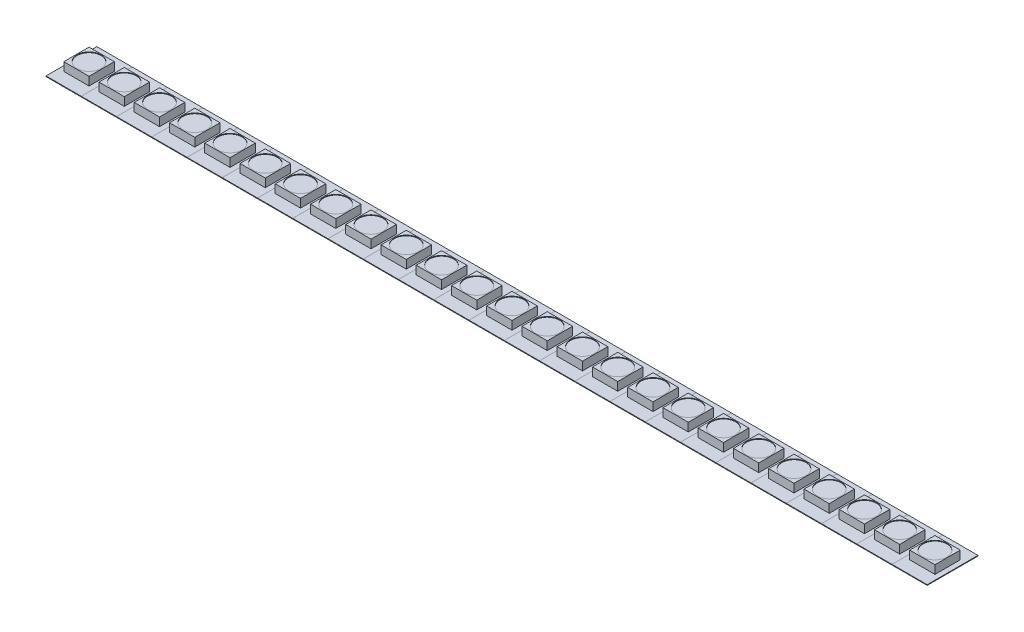
from build123d import *

# Parameters (mm, degrees)
SKETCH1_W           = 6.9088
SKETCH1_H           = 9.9568
BOSS_EXTRUDE1_DEPTH = 0.127
SKETCH3_W           = 4.953
SKETCH3_H           = 4.953
BOSS_EXTRUDE3_DEPTH = 1.651
SKETCH5_R           = 2.348345572
CUT_EXTRUDE1_DEPTH  = 0.127
LPATTERN1_COUNT     = 25
LPATTERN1_PITCH     = 6.9088


with BuildPart() as part:
    # Sketch1 → Boss-Extrude1 (new body)
    with BuildSketch(Plane(origin=(0, 0, 0), x_dir=(1, 0, 0), z_dir=(0, 1, 0))):
        Rectangle(SKETCH1_W, SKETCH1_H)
    extrude(amount=BOSS_EXTRUDE1_DEPTH)

    # Sketch3 → Boss-Extrude3 (add)
    with BuildSketch(Plane(origin=(0, 0.127, 0), x_dir=(1, 0, 0), z_dir=(0, 1, 0))):
        Rectangle(SKETCH3_W, SKETCH3_H)
    extrude(amount=BOSS_EXTRUDE3_DEPTH)

    # Sketch5 → Cut-Extrude1 (cut)
    with BuildSketch(Plane(origin=(0, 1.778, 0), x_dir=(1, 0, 0), z_dir=(0, 1, 0))):
        Circle(SKETCH5_R)
    extrude(amount=-CUT_EXTRUDE1_DEPTH, mode=Mode.SUBTRACT)


with BuildPart() as lpattern1_1:
    # LPattern1: pattern copy
    add(part.part.moved(Location(Vector(1, 0, 0) * (1 * LPATTERN1_PITCH))))


with BuildPart() as lpattern1_2:
    # LPattern1: pattern copy
    add(part.part.moved(Location(Vector(1, 0, 0) * (2 * LPATTERN1_PITCH))))


with BuildPart() as lpattern1_3:
    # LPattern1: pattern copy
    add(part.part.moved(Location(Vector(1, 0, 0) * (3 * LPATTERN1_PITCH))))


with BuildPart() as lpattern1_4:
    # LPattern1: pattern copy
    add(part.part.moved(Location(Vector(1, 0, 0) * (4 * LPATTERN1_PITCH))))


with BuildPart() as lpattern1_5:
    # LPattern1: pattern copy
    add(part.part.moved(Location(Vector(1, 0, 0) * (5 * LPATTERN1_PITCH))))


with BuildPart() as lpattern1_6:
    # LPattern1: pattern copy
    add(part.part.moved(Location(Vector(1, 0, 0) * (6 * LPATTERN1_PITCH))))


with BuildPart() as lpattern1_7:
    # LPattern1: pattern copy
    add(part.part.moved(Location(Vector(1, 0, 0) * (7 * LPATTERN1_PITCH))))


with BuildPart() as lpattern1_8:
    # LPattern1: pattern copy
    add(part.part.moved(Location(Vector(1, 0, 0) * (8 * LPATTERN1_PITCH))))


with BuildPart() as lpattern1_9:
    # LPattern1: pattern copy
    add(part.part.moved(Location(Vector(1, 0, 0) * (9 * LPATTERN1_PITCH))))


with BuildPart() as lpattern1_10:
    # LPattern1: pattern copy
    add(part.part.moved(Location(Vector(1, 0, 0) * (10 * LPATTERN1_PITCH))))


with BuildPart() as lpattern1_11:
    # LPattern1: pattern copy
    add(part.part.moved(Location(Vector(1, 0, 0) * (11 * LPATTERN1_PITCH))))


with BuildPart() as lpattern1_12:
    # LPattern1: pattern copy
    add(part.part.moved(Location(Vector(1, 0, 0) * (12 * LPATTERN1_PITCH))))


with BuildPart() as lpattern1_13:
    # LPattern1: pattern copy
    add(part.part.moved(Location(Vector(1, 0, 0) * (13 * LPATTERN1_PITCH))))


with BuildPart() as lpattern1_14:
    # LPattern1: pattern copy
    add(part.part.moved(Location(Vector(1, 0, 0) * (14 * LPATTERN1_PITCH))))


with BuildPart() as lpattern1_15:
    # LPattern1: pattern copy
    add(part.part.moved(Location(Vector(1, 0, 0) * (15 * LPATTERN1_PITCH))))


with BuildPart() as lpattern1_16:
    # LPattern1: pattern copy
    add(part.part.moved(Location(Vector(1, 0, 0) * (16 * LPATTERN1_PITCH))))


with BuildPart() as lpattern1_17:
    # LPattern1: pattern copy
    add(part.part.moved(Location(Vector(1, 0, 0) * (17 * LPATTERN1_PITCH))))


with BuildPart() as lpattern1_18:
    # LPattern1: pattern copy
    add(part.part.moved(Location(Vector(1, 0, 0) * (18 * LPATTERN1_PITCH))))


with BuildPart() as lpattern1_19:
    # LPattern1: pattern copy
    add(part.part.moved(Location(Vector(1, 0, 0) * (19 * LPATTERN1_PITCH))))


with BuildPart() as lpattern1_20:
    # LPattern1: pattern copy
    add(part.part.moved(Location(Vector(1, 0, 0) * (20 * LPATTERN1_PITCH))))


with BuildPart() as lpattern1_21:
    # LPattern1: pattern copy
    add(part.part.moved(Location(Vector(1, 0, 0) * (21 * LPATTERN1_PITCH))))


with BuildPart() as lpattern1_22:
    # LPattern1: pattern copy
    add(part.part.moved(Location(Vector(1, 0, 0) * (22 * LPATTERN1_PITCH))))


with BuildPart() as lpattern1_23:
    # LPattern1: pattern copy
    add(part.part.moved(Location(Vector(1, 0, 0) * (23 * LPATTERN1_PITCH))))


with BuildPart() as lpattern1_24:
    # LPattern1: pattern copy
    add(part.part.moved(Location(Vector(1, 0, 0) * (24 * LPATTERN1_PITCH))))


solid = Compound([part.part, lpattern1_1.part, lpattern1_2.part, lpattern1_3.part, lpattern1_4.part, lpattern1_5.part, lpattern1_6.part, lpattern1_7.part, lpattern1_8.part, lpattern1_9.part, lpattern1_10.part, lpattern1_11.part, lpattern1_12.part, lpattern1_13.part, lpattern1_14.part, lpattern1_15.part, lpattern1_16.part, lpattern1_17.part, lpattern1_18.part, lpattern1_19.part, lpattern1_20.part, lpattern1_21.part, lpattern1_22.part, lpattern1_23.part, lpattern1_24.part])
